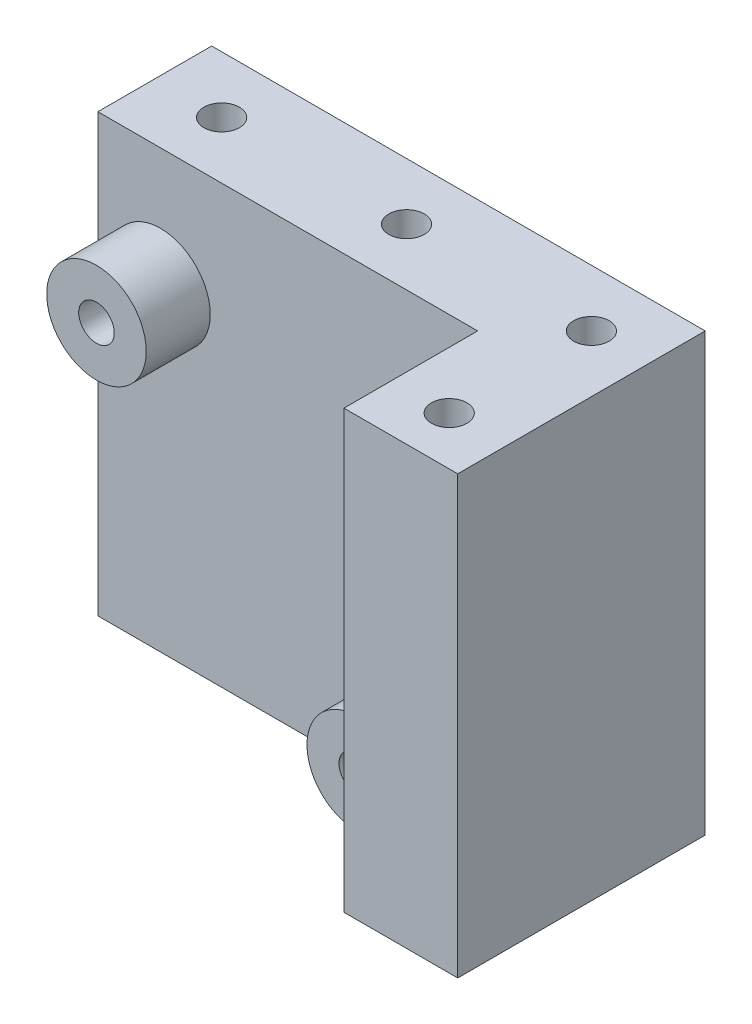
from build123d import *

# Parameters (mm, degrees)
ESQUISSE1_W             = 34.7
ESQUISSE1_H             = 30.7
BOSS_EXTRU_1_DEPTH      = 8
ESQUISSE2_R             = 3.5
ESQUISSE2_R_2           = 1.25
BOSS_EXTRU_2_DEPTH      = 4.5
ESQUISSE3_W             = 8
ESQUISSE3_H             = 30.7
BOSS_EXTRU_3_DEPTH      = 9.4
ESQUISSE4_R             = 1.25
ENL_V_MAT_EXTRU_1_DEPTH = 31.7
ESQUISSE6_R             = 1.25
ENL_V_MAT_EXTRU_2_DEPTH = 9


with BuildPart() as part:
    # Esquisse1 → Boss.-Extru.1 (new body)
    with BuildSketch(Plane.XY):
        with Locations((-17.35, 0)):
            Rectangle(ESQUISSE1_W, ESQUISSE1_H)
    extrude(amount=BOSS_EXTRU_1_DEPTH)

    # Esquisse2 → Boss.-Extru.2 (add, symmetric)
    with BuildSketch(Plane.XY.offset(8)):
        with Locations((-30.3, 6.95)):
            Circle(ESQUISSE2_R)
        with Locations((-30.3, 6.95)):
            Circle(ESQUISSE2_R_2, mode=Mode.SUBTRACT)
        with Locations((-12, -11.35)):
            Circle(ESQUISSE2_R)
        with Locations((-12, -11.35)):
            Circle(ESQUISSE2_R_2, mode=Mode.SUBTRACT)
    extrude(amount=BOSS_EXTRU_2_DEPTH, both=True)

    # Esquisse3 → Boss.-Extru.3 (add)
    with BuildSketch(Plane.XY.offset(8)):
        with Locations((-4, 0)):
            Rectangle(ESQUISSE3_W, ESQUISSE3_H)
    extrude(amount=BOSS_EXTRU_3_DEPTH)

    # Esquisse4 → Enlèv. mat.-Extru.1 (cut, through all)
    with BuildSketch(Plane(origin=(0, 15.35, 0), x_dir=(1, 0, 0), z_dir=(0, 1, 0))):
        with Locations((-4, -14)):
            Circle(ESQUISSE4_R)
        with Locations((-4, -4)):
            Circle(ESQUISSE4_R)
        with Locations((-17, -4)):
            Circle(ESQUISSE4_R)
        with Locations((-30, -4)):
            Circle(ESQUISSE4_R)
    extrude(amount=-ENL_V_MAT_EXTRU_1_DEPTH, mode=Mode.SUBTRACT)

    # Esquisse6 → Enlèv. mat.-Extru.2 (cut, through all)
    with BuildSketch(Plane.XY.offset(8)):
        with Locations((-30.3, 6.95)):
            Circle(ESQUISSE6_R)
        with Locations((-12, -11.35)):
            Circle(ESQUISSE6_R)
    extrude(amount=-ENL_V_MAT_EXTRU_2_DEPTH, mode=Mode.SUBTRACT)


solid = part.part
